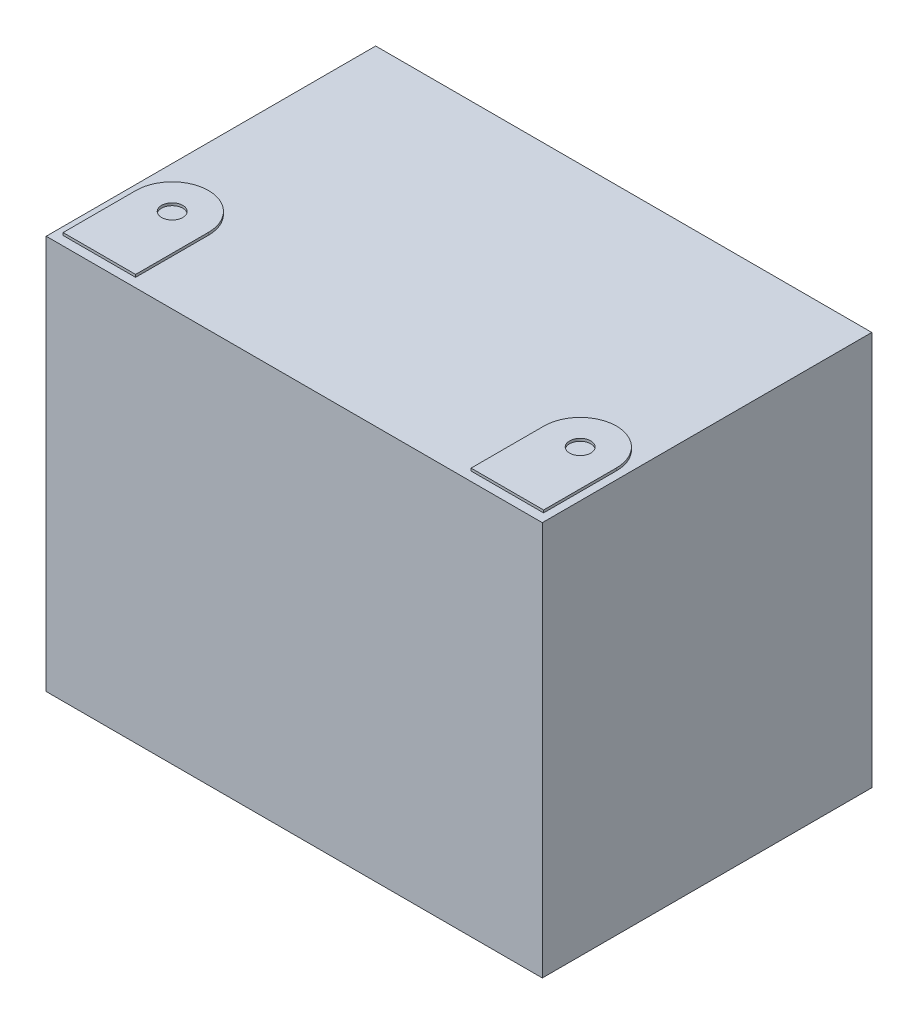
from build123d import *

# Parameters (mm, degrees)
SKETCH1_W           = 195
SKETCH1_H           = 129.5
BOSS_EXTRUDE1_DEPTH = 155
SKETCH2_R           = 4.164052638
BOSS_EXTRUDE2_DEPTH = 1


with BuildPart() as part:
    # Sketch1 → Boss-Extrude1 (new body)
    with BuildSketch(Plane(origin=(0, 0, 0), x_dir=(1, 0, 0), z_dir=(0, 1, 0))):
        Rectangle(SKETCH1_W, SKETCH1_H)
    extrude(amount=-BOSS_EXTRUDE1_DEPTH)

    # Sketch2 → Boss-Extrude2 (add)
    with BuildSketch(Plane(origin=(0, 0, 0), x_dir=(1, 0, 0), z_dir=(0, 1, 0))):
        with BuildLine():
            Line((-94.433753678, -61.181302267), (-65.933753678, -61.181302267))
            Line((-65.933753678, -61.181302267), (-65.933753678, -32.546661398))
            ThreePointArc((-65.933753678, -32.546661398), (-80.183753678, -18.296661398), (-94.433753678, -32.546661398))
            Line((-94.433753678, -32.546661398), (-94.433753678, -61.181302267))
        make_face()
        with Locations((-80.183753678, -32.546661398)):
            Circle(SKETCH2_R, mode=Mode.SUBTRACT)
    boss_extrude2 = extrude(amount=BOSS_EXTRUDE2_DEPTH)

    # Mirror1: Boss-Extrude2 across plane
    add(boss_extrude2.mirror(Plane(origin=(0, 0, 0), x_dir=(0, 0, 1), z_dir=(1, 0, 0))))


solid = part.part
